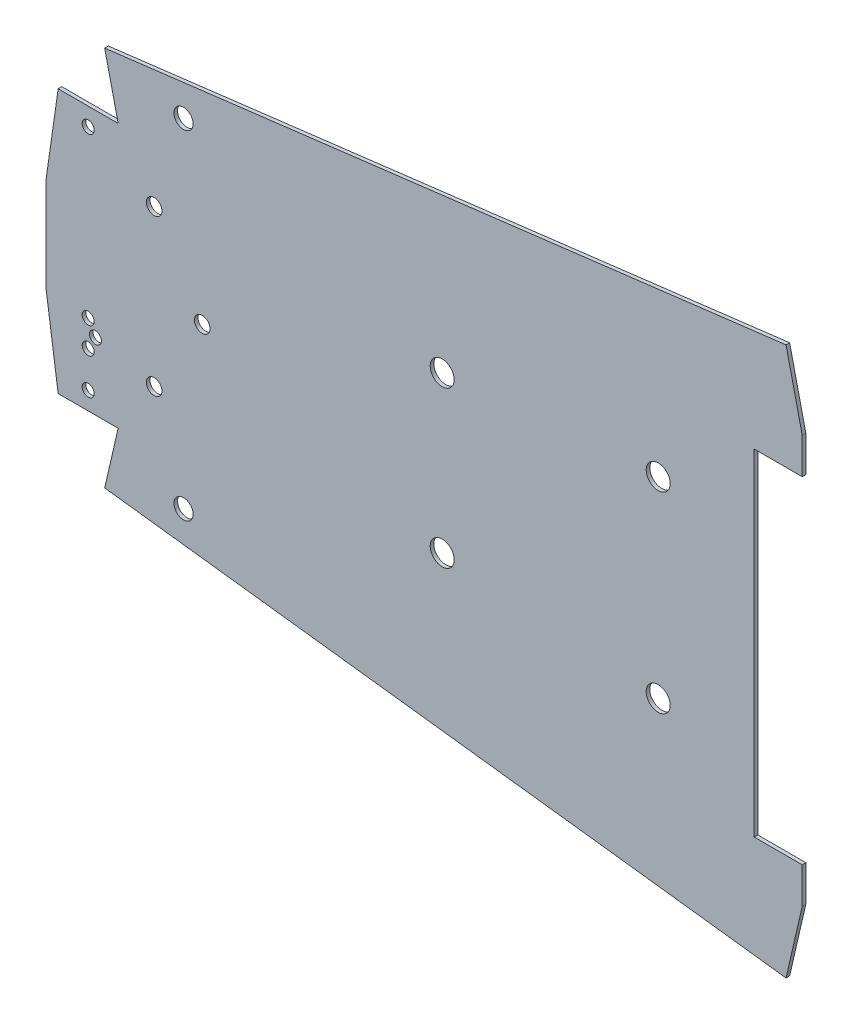
from build123d import *

# Parameters (mm, degrees)
SKIZZE1_R                            = 2.5
SKIZZE1_R_2                          = 5
SKIZZE1_R_3                          = 3.25
SKIZZE1_R_4                          = 4
AUFSATZ_LINEAR_AUSTRAGEN2_DEPTH      = 1.5
AUFSATZ_LINEAR_AUSTRAGEN2_DEPTH_BACK = 0.0001


with BuildPart() as part:
    # Skizze1 → Aufsatz-Linear austragen2 (new body, two sides)
    with BuildSketch(Plane.XY) as aufsatz_linear_austragen2_sk:
        Polygon((-241.005153528, -55), (-216.005153528, -55), (-221.628929887, -79.35925162), (62.246314842, -114.231101944), (68.994846472, -85), (68.994846472, -70), (48.994846472, -70), (48.994846472, 70), (68.994846472, 70), (68.994846472, 85), (62.246314842, 114.231101944), (-221.628929887, 79.35925162), (-216.005153528, 55), (-241.005153528, 55), (-246.005153528, 20), (-246.005153528, -20), align=None)
        with Locations((-228.505153528, -47.5)):
            Circle(SKIZZE1_R, mode=Mode.SUBTRACT)
        with Locations((-228.505153528, -32.5)):
            Circle(SKIZZE1_R, mode=Mode.SUBTRACT)
        with Locations((-228.505153528, -21.5)):
            Circle(SKIZZE1_R, mode=Mode.SUBTRACT)
        with Locations((-225.505153528, -27)):
            Circle(SKIZZE1_R, mode=Mode.SUBTRACT)
        with Locations((-228.505153528, 47.5)):
            Circle(SKIZZE1_R, mode=Mode.SUBTRACT)
        with Locations((8.994846472, 40)):
            Circle(SKIZZE1_R_2, mode=Mode.SUBTRACT)
        with Locations((-201.005153528, -32.5)):
            Circle(SKIZZE1_R_3, mode=Mode.SUBTRACT)
        with Locations((-181.005153528, 0)):
            Circle(SKIZZE1_R_3, mode=Mode.SUBTRACT)
        with Locations((-81.005153528, -32.5)):
            Circle(SKIZZE1_R_2, mode=Mode.SUBTRACT)
        with Locations((8.994846472, -40)):
            Circle(SKIZZE1_R_2, mode=Mode.SUBTRACT)
        with Locations((-201.005153528, 32.5)):
            Circle(SKIZZE1_R_3, mode=Mode.SUBTRACT)
        with Locations((-81.005153528, 32.5)):
            Circle(SKIZZE1_R_2, mode=Mode.SUBTRACT)
        with Locations((-188.77946315, -70.434923444)):
            Circle(SKIZZE1_R_4, mode=Mode.SUBTRACT)
        with Locations((-188.77946315, 70.434923444)):
            Circle(SKIZZE1_R_4, mode=Mode.SUBTRACT)
    extrude(amount=AUFSATZ_LINEAR_AUSTRAGEN2_DEPTH)
    extrude(aufsatz_linear_austragen2_sk.sketch, amount=-AUFSATZ_LINEAR_AUSTRAGEN2_DEPTH_BACK)


solid = part.part
